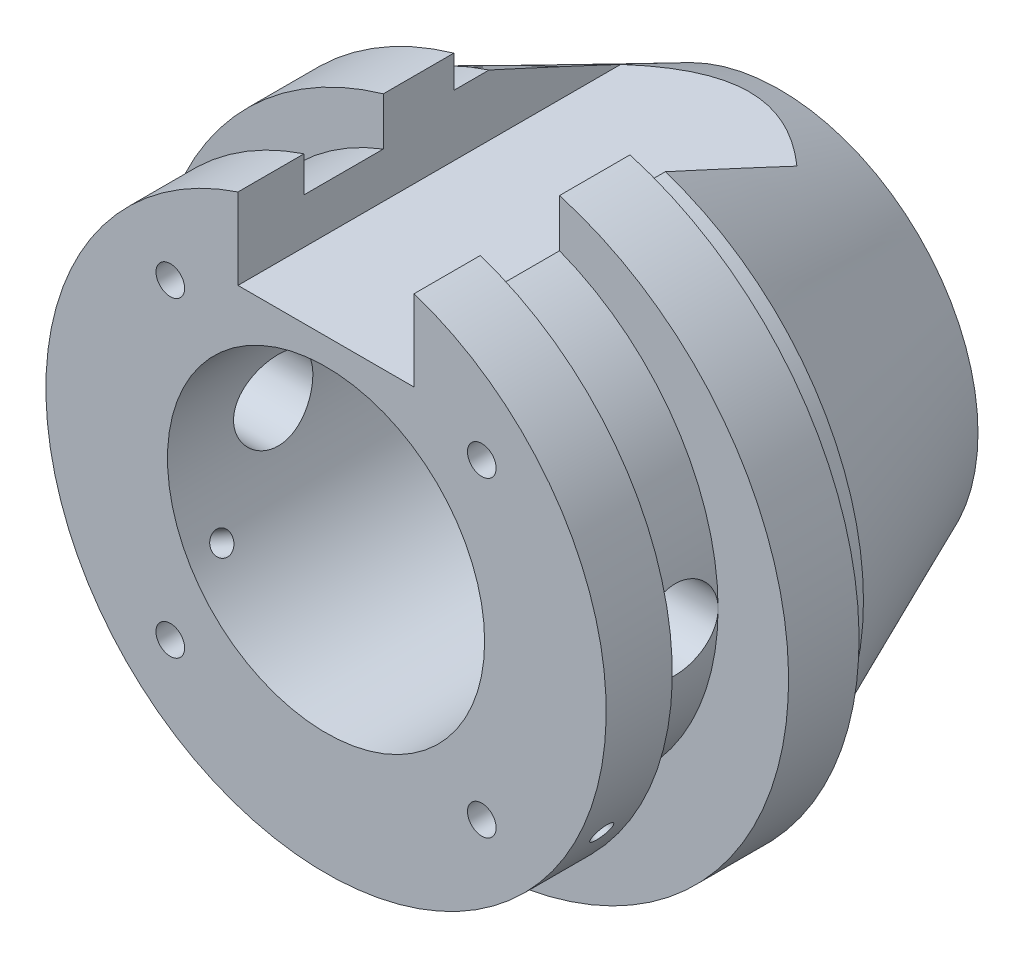
from build123d import *

# Parameters (mm, degrees)
ESQUISSE1_R                  = 36
BASE_EXTRUSION_DEPTH         = 8
ESQUISSE2_R                  = 32.5
BOSS_EXTRU_1_DEPTH           = 4
ESQUISSE4_R                  = 28
BOSS_EXTRU_2_DEPTH           = 9
ESQUISSE5_R                  = 31.8
BOSS_EXTRU_3_DEPTH           = 7.5
ESQUISSE6_R                  = 18
ENL_V_MAT_EXTRU_1_DEPTH      = 52.5
ESQUISSE10_W                 = 20
ESQUISSE10_H                 = 14.61003861
ENL_V_MAT_EXTRU_5_DEPTH      = 52.5
R_P_TITION_CIRCULAIRE1_COUNT = 4
ESQUISSE13_R                 = 4.5
ENL_V_MAT_EXTRU_6_DEPTH      = 37
ENL_V_MAT_EXTRU_6_DEPTH_BACK = 37
ENL_V_START                  = -31.8
ESQUISSE14_R                 = 1.23
ENL_V_MAT_EXTRU_7_DEPTH      = 13.842074
R_P_TITION_CIRCULAIRE2_COUNT = 2
R_P_TITION_CIRCULAIRE2_ANGLE = 120


with BuildPart() as part:
    # Esquisse1 → Base-Extrusion (new body)
    with BuildSketch(Plane.XY):
        Circle(ESQUISSE1_R)
    extrude(amount=BASE_EXTRUSION_DEPTH)

    # Esquisse2 → Boss.-Extru.1 (add)
    with BuildSketch(Plane(origin=(0, 0, 0), x_dir=(-1, 0, 0), z_dir=(0, 0, -1))):
        Circle(ESQUISSE2_R)
    extrude(amount=BOSS_EXTRU_1_DEPTH)

    # Esquisse3 → Boss.-Révol.1 (revolve)
    with BuildSketch(Plane(origin=(0, 0, 0), x_dir=(0, 0, -1), z_dir=(1, 0, 0))):
        Polygon((4, 32.5), (27, 22.499315376), (27, 0), (4, 0), align=None)
    revolve(axis=Axis((0, 0, 0), (0, 0, -1)))

    # Esquisse4 → Boss.-Extru.2 (add)
    with BuildSketch(Plane.XY.offset(8)):
        with Locations((0, 3)):
            Circle(ESQUISSE4_R)
    extrude(amount=BOSS_EXTRU_2_DEPTH)

    # Esquisse5 → Boss.-Extru.3 (add)
    with BuildSketch(Plane.XY.offset(17)):
        with Locations((0, 3)):
            Circle(ESQUISSE5_R)
    extrude(amount=BOSS_EXTRU_3_DEPTH)

    # Esquisse6 → Enlèv. mat.-Extru.1 (cut, through all)
    with BuildSketch(Plane.XY.offset(24.5)):
        with Locations((0, 3)):
            Circle(ESQUISSE6_R)
    extrude(amount=-ENL_V_MAT_EXTRU_1_DEPTH, mode=Mode.SUBTRACT)

    # Esquisse10 → Enlèv. mat.-Extru.5 (cut, through all)
    with BuildSketch(Plane.XY.offset(24.5)):
        with Locations((0, 31.305019305)):
            Rectangle(ESQUISSE10_W, ESQUISSE10_H)
    extrude(amount=-ENL_V_MAT_EXTRU_5_DEPTH, mode=Mode.SUBTRACT)

    # Esquisse11 → Perçage1 (revolve, cut)
    with BuildSketch(Plane(origin=(-17.67766953, 20.67766953, 24.5), x_dir=(0, -1, 0), z_dir=(1, 0, 0))):
        Polygon((0, 0), (0, 12.976398506), (1.625, 12), (1.625, 0), align=None)
    per_age1 = revolve(axis=Axis((-17.67766953, 20.67766953, 28.744199587), (0, 0, -1)), mode=Mode.SUBTRACT)

    # Répétition circulaire1: Perçage1 ×4 about axis
    r_p_tition_circulaire1_axis = Axis((0, 3, 0), (0, 0, 1))
    for i in range(1, R_P_TITION_CIRCULAIRE1_COUNT):
        add(per_age1.rotate(r_p_tition_circulaire1_axis, i * 360 / R_P_TITION_CIRCULAIRE1_COUNT), mode=Mode.SUBTRACT)

    # Esquisse13 → Enlèv. mat.-Extru.6 (cut, two sides)
    with BuildSketch(Plane(origin=(0, 0, 0), x_dir=(0, 0, -1), z_dir=(1, 0, 0))) as enl_v_mat_extru_6_sk:
        with Locations((-12.5, 3)):
            Circle(ESQUISSE13_R)
    extrude(amount=ENL_V_MAT_EXTRU_6_DEPTH, mode=Mode.SUBTRACT)
    extrude(enl_v_mat_extru_6_sk.sketch, amount=-ENL_V_MAT_EXTRU_6_DEPTH_BACK, mode=Mode.SUBTRACT)

    # Esquisse14 → Enlèv. mat.-Extru.7 (cut)
    with BuildSketch(Plane(origin=(-1.299038106, 0.75, 0), x_dir=(0, 0, 1), z_dir=(-0.866025404, 0.5, 0)).offset(ENL_V_START)):
        with Locations((20.75, 2.598076211)):
            Circle(ESQUISSE14_R)
    enl_v_mat_extru_7 = extrude(amount=ENL_V_MAT_EXTRU_7_DEPTH, mode=Mode.SUBTRACT)

    # Répétition circulaire2: Enlèv. mat.-Extru.7 ×2 about axis
    r_p_tition_circulaire2_axis = Axis((0, 3, 0), (0, 0, -1))
    for i in range(1, R_P_TITION_CIRCULAIRE2_COUNT):
        add(enl_v_mat_extru_7.rotate(r_p_tition_circulaire2_axis, i * R_P_TITION_CIRCULAIRE2_ANGLE / (R_P_TITION_CIRCULAIRE2_COUNT - 1)), mode=Mode.SUBTRACT)


solid = part.part
